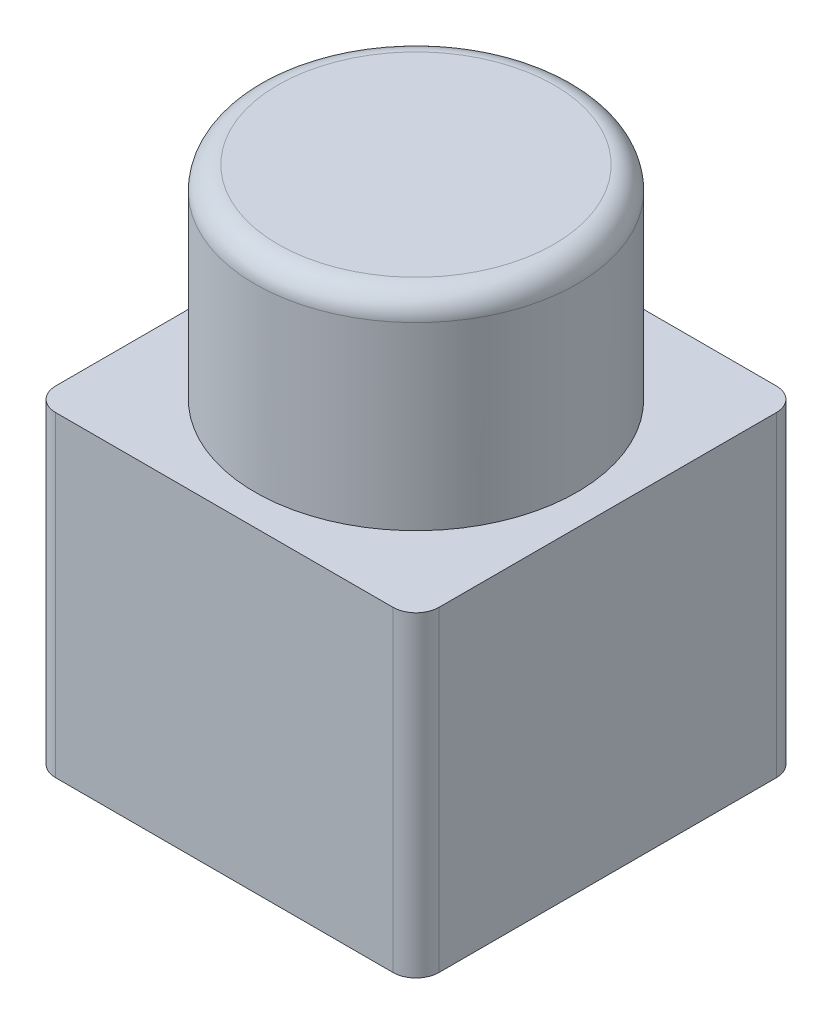
from build123d import *

# Parameters (mm, degrees)
SKETCH1_W           = 50
SKETCH1_H           = 50
BOSS_EXTRUDE1_DEPTH = 41.25
SKETCH2_R           = 1.5
CUT_EXTRUDE1_DEPTH  = 6
SKETCH3_R           = 21
BOSS_EXTRUDE2_DEPTH = 26.5
FILLET1_R           = 3


with BuildPart() as part:
    # Sketch1 → Boss-Extrude1 (new body)
    with BuildSketch(Plane(origin=(0, 0, 0), x_dir=(1, 0, 0), z_dir=(0, 1, 0))):
        with Locations((25, 25)):
            Rectangle(SKETCH1_W, SKETCH1_H)
    extrude(amount=BOSS_EXTRUDE1_DEPTH)

    # Sketch2 → Cut-Extrude1 (cut)
    with BuildSketch(Plane.XZ):
        with Locations((5, -4.999999995)):
            Circle(SKETCH2_R)
        with Locations((45, -45.000000005)):
            Circle(SKETCH2_R)
    extrude(amount=-CUT_EXTRUDE1_DEPTH, mode=Mode.SUBTRACT)

    # Sketch3 → Boss-Extrude2 (add)
    with BuildSketch(Plane(origin=(0, 41.25, 0), x_dir=(1, 0, 0), z_dir=(0, 1, 0))):
        with Locations((25, 25)):
            Circle(SKETCH3_R)
    extrude(amount=BOSS_EXTRUDE2_DEPTH)

    # Fillet1
    fillet1_edges = [part.edges().sort_by_distance(p)[0] for p in [
        (4, 67.75, -25),
        (0, 20.625, 0),
        (50, 20.625, 0),
        (50, 20.625, -50),
        (0, 20.625, -50),
    ]]
    fillet(fillet1_edges, radius=FILLET1_R)


solid = part.part
